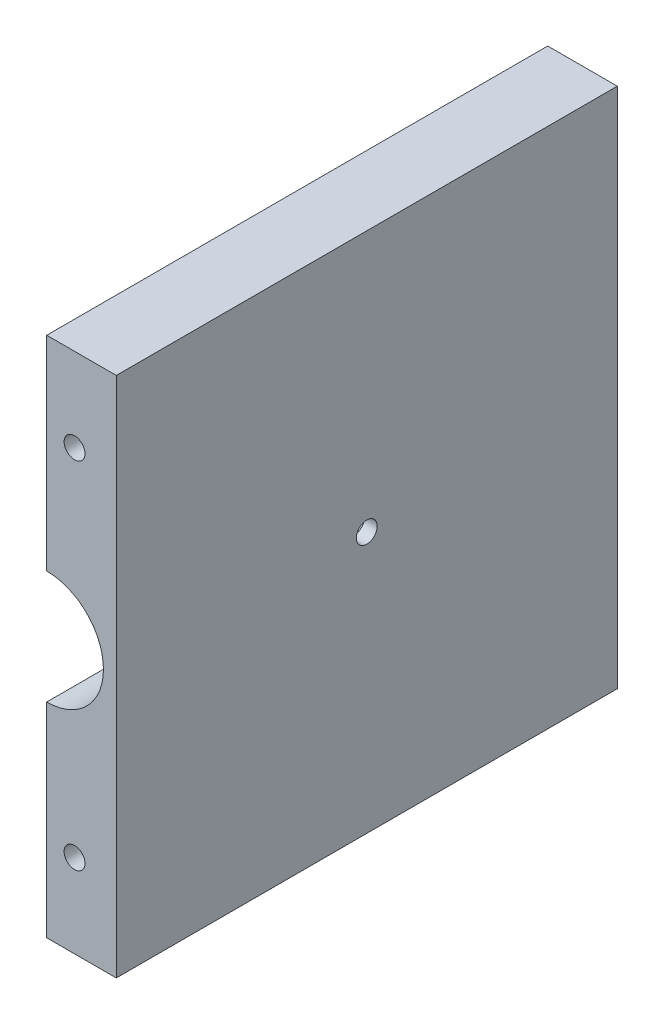
from build123d import *

# Parameters (mm, degrees)
SALIENTE_EXTRUIR1_DEPTH = 72
CROQUIS2_R              = 1.5
CORTAR_EXTRUIR1_DEPTH   = 73
CROQUIS3_R              = 1.5
CORTAR_EXTRUIR2_DEPTH   = 11


with BuildPart() as part:
    # Croquis1 → Saliente-Extruir1 (new body)
    with BuildSketch(Plane.XY):
        with BuildLine():
            Line((0, 0), (10, 0))
            Line((10, 0), (10, 75))
            Line((10, 75), (0, 75))
            Line((0, 75), (0, 45.65))
            ThreePointArc((0, 45.65), (8.15, 37.5), (0, 29.35))
            Line((0, 29.35), (0, 0))
        make_face()
    extrude(amount=SALIENTE_EXTRUIR1_DEPTH)

    # Croquis2 → Cortar-Extruir1 (cut, through all)
    with BuildSketch(Plane.XY.offset(72)):
        with Locations((4, 63)):
            Circle(CROQUIS2_R)
        with Locations((4, 12)):
            Circle(CROQUIS2_R)
    extrude(amount=-CORTAR_EXTRUIR1_DEPTH, mode=Mode.SUBTRACT)

    # Croquis3 → Cortar-Extruir2 (cut, through all)
    with BuildSketch(Plane(origin=(10, 0, 0), x_dir=(0, 0, -1), z_dir=(1, 0, 0))):
        with Locations(Location((-36, 37.5, 0), (0, 0, 90))):  # turned: the seam where the file's is
            Circle(CROQUIS3_R)
    extrude(amount=-CORTAR_EXTRUIR2_DEPTH, mode=Mode.SUBTRACT)


solid = part.part
